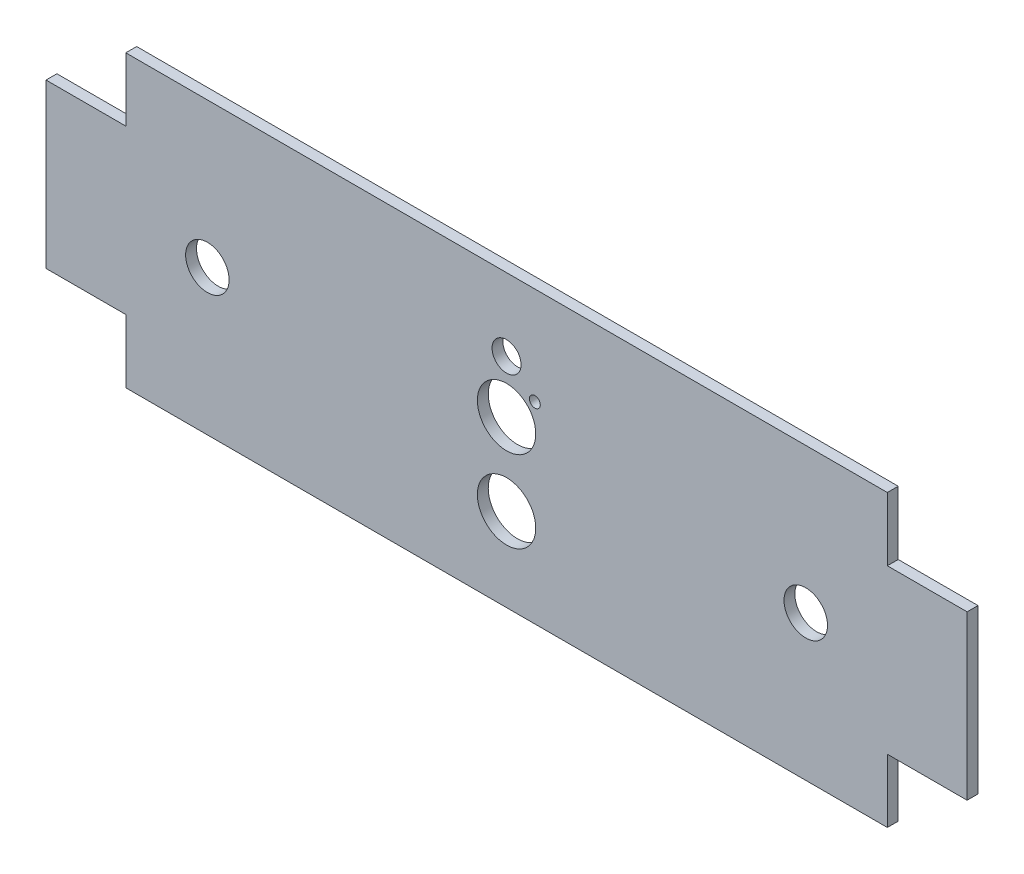
from build123d import *

# Parameters (mm, degrees)
CROQUIS1_W              = 22
CROQUIS1_H              = 45
CROQUIS1_W_2            = 210
CROQUIS1_H_2            = 60
SALIENTE_EXTRUIR1_DEPTH = 3
CORTAR_EXTRUIR1_REACH   = 5
CROQUIS2_R              = 6
CORTAR_EXTRUIR2_REACH   = 5
CROQUIS3_R              = 4
CROQUIS4_W              = 210
CROQUIS4_H              = 10
SALIENTE_EXTRUIR2_DEPTH = 3
CROQUIS5_W              = 210
CROQUIS5_H              = 10
SALIENTE_EXTRUIR3_DEPTH = 3
CROQUIS6_R              = 1.5
CROQUIS6_R_2            = 8.05
CORTAR_EXTRUIR3_DEPTH   = 7


with BuildPart() as part:
    # Croquis1 → Saliente-Extruir1 (new body)
    with BuildSketch(Plane.XY):
        with Locations((-116, 0)):
            Rectangle(CROQUIS1_W, CROQUIS1_H)
        Rectangle(CROQUIS1_W_2, CROQUIS1_H_2)
        with Locations((116, 0)):
            Rectangle(CROQUIS1_W, CROQUIS1_H)
    extrude(amount=SALIENTE_EXTRUIR1_DEPTH)

    # Croquis2 → Cortar-Extruir1 (cut, up to next)
    with BuildSketch(Plane.XY.offset(3), mode=Mode.PRIVATE) as cortar_extruir1_sk1:
        with Locations((82.5, 0)):
            Circle(CROQUIS2_R)
    cortar_extruir1_tool1 = extrude(cortar_extruir1_sk1.sketch, amount=-CORTAR_EXTRUIR1_REACH, mode=Mode.PRIVATE) & part.part
    add(cortar_extruir1_tool1.solids().sort_by_distance((82.5, 0, 3))[0], mode=Mode.SUBTRACT)
    # Croquis2 → Cortar-Extruir1 (cut, up to next)
    with BuildSketch(Plane.XY.offset(3), mode=Mode.PRIVATE) as cortar_extruir1_sk2:
        with Locations((-82.5, 0)):
            Circle(CROQUIS2_R)
    cortar_extruir1_tool2 = extrude(cortar_extruir1_sk2.sketch, amount=-CORTAR_EXTRUIR1_REACH, mode=Mode.PRIVATE) & part.part
    add(cortar_extruir1_tool2.solids().sort_by_distance((-82.5, 0, 3))[0], mode=Mode.SUBTRACT)

    # Croquis3 → Cortar-Extruir2 (cut, up to next)
    with BuildSketch(Plane.XY.offset(3), mode=Mode.PRIVATE) as cortar_extruir2_sk1:
        with Locations((0, 20)):
            Circle(CROQUIS3_R)
    cortar_extruir2_tool1 = extrude(cortar_extruir2_sk1.sketch, amount=-CORTAR_EXTRUIR2_REACH, mode=Mode.PRIVATE) & part.part
    add(cortar_extruir2_tool1.solids().sort_by_distance((0, 20, 3))[0], mode=Mode.SUBTRACT)

    # Croquis4 → Saliente-Extruir2 (add)
    with BuildSketch(Plane.XY.offset(3)):
        with Locations((0, -35)):
            Rectangle(CROQUIS4_W, CROQUIS4_H)
    extrude(amount=-SALIENTE_EXTRUIR2_DEPTH)

    # Croquis5 → Saliente-Extruir3 (add)
    with BuildSketch(Plane.XY.offset(3)):
        with Locations((0, 35)):
            Rectangle(CROQUIS5_W, CROQUIS5_H)
    extrude(amount=-SALIENTE_EXTRUIR3_DEPTH)

    # Croquis6 → Cortar-Extruir3 (cut)
    with BuildSketch(Plane(origin=(0, 0, 0), x_dir=(-1, 0, 0), z_dir=(0, 0, -1))):
        with Locations((-7.8, 13.05)):
            Circle(CROQUIS6_R)
        with Locations((0, 5.5)):
            Circle(CROQUIS6_R_2)
        with Locations((0, -17)):
            Circle(CROQUIS6_R_2)
    extrude(amount=-CORTAR_EXTRUIR3_DEPTH, mode=Mode.SUBTRACT)


solid = part.part
